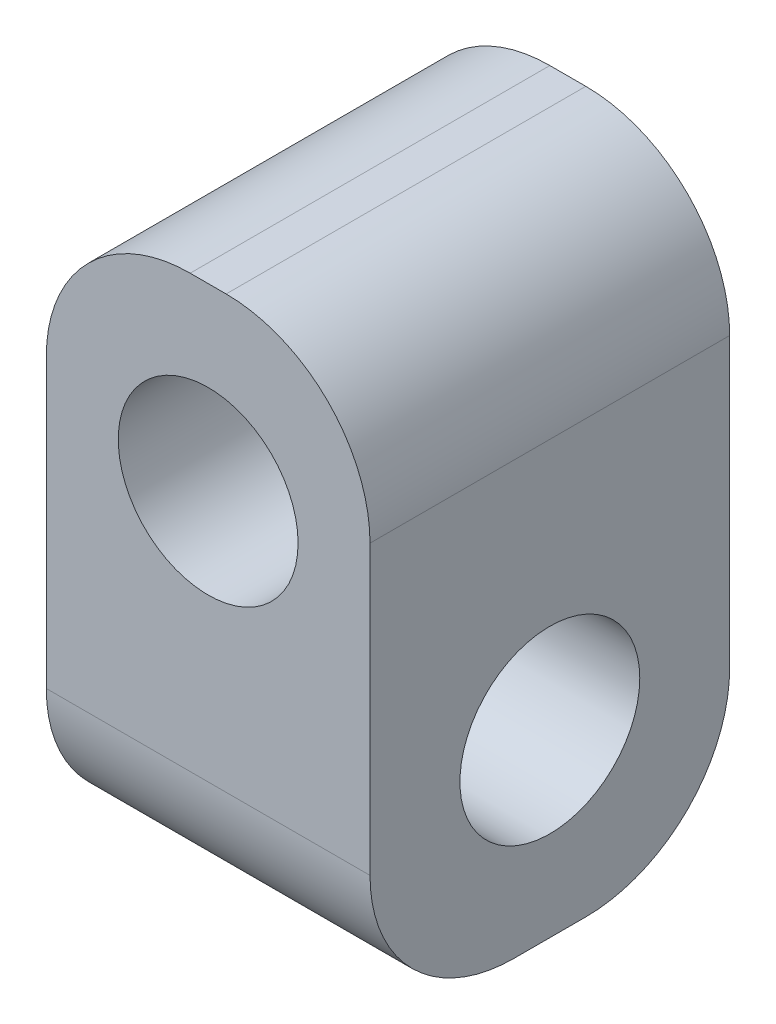
from build123d import *

# Parameters (mm, degrees)
SKETCH1_R           = 12.5
BOSS_EXTRUDE1_DEPTH = 50
SKETCH2_R           = 12.5
BOSS_EXTRUDE2_DEPTH = 22.5


with BuildPart() as part:
    # Sketch1 → Boss-Extrude1 (new body)
    with BuildSketch(Plane.XY):
        with BuildLine():
            Line((-2.5, 25), (2.5, 25))
            ThreePointArc((2.5, 25), (16.642135624, 19.142135624), (22.5, 5))
            Line((22.5, 5), (22.5, -15))
            Line((22.5, -15), (-22.5, -15))
            Line((-22.5, -15), (-22.5, 5))
            ThreePointArc((-22.5, 5), (-16.642135624, 19.142135624), (-2.5, 25))
        make_face()
        Circle(SKETCH1_R, mode=Mode.SUBTRACT)
    extrude(amount=BOSS_EXTRUDE1_DEPTH)

    # Sketch2 → Boss-Extrude2 (add, symmetric)
    with BuildSketch(Plane(origin=(0, 0, 0), x_dir=(0, 0, -1), z_dir=(1, 0, 0))):
        with BuildLine():
            Line((-50, -15), (-50, -35))
            ThreePointArc((-50, -35), (-44.142135624, -49.142135624), (-30, -55))
            Line((-30, -55), (-20, -55))
            ThreePointArc((-20, -55), (-5.857864376, -49.142135624), (0, -35))
            Line((0, -35), (0, -15))
            Line((0, -15), (-50, -15))
        make_face()
        with Locations((-25, -30)):
            Circle(SKETCH2_R, mode=Mode.SUBTRACT)
    extrude(amount=BOSS_EXTRUDE2_DEPTH, both=True)


solid = part.part
